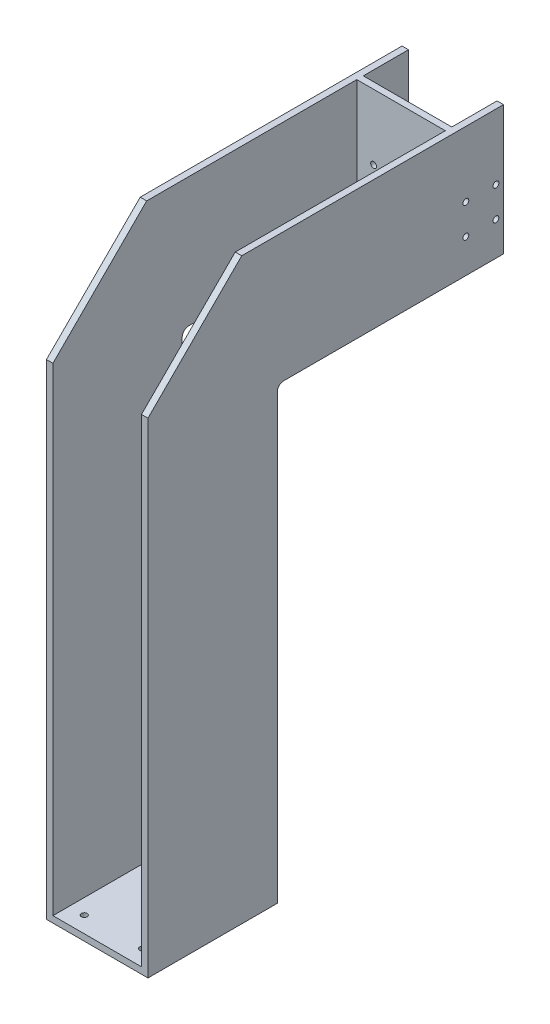
from build123d import *

# Parameters (mm, degrees)
BOSS_EXTRUDE1_DEPTH      = 10
BOSS_EXTRUDE1_DEPTH_BACK = 147
SKETCH3_W                = 137
SKETCH3_H                = 550
CUT_EXTRUDE1_DEPTH       = 885
SKETCH4_W                = 137
SKETCH4_H                = 200
BOSS_EXTRUDE2_DEPTH      = 10
SKETCH5_R                = 4.5
CUT_EXTRUDE2_DEPTH       = 158
CUT_EXTRUDE3_REACH       = 82
SKETCH6_R                = 4.5
SKETCH6_R_2              = 8
CUT_EXTRUDE4_REACH       = 12
SKETCH7_R                = 4.5
SKETCH7_R_2              = 5
FILLET1_R                = 10


with BuildPart() as part:
    # Sketch1 → Boss-Extrude1 (new body, two sides)
    with BuildSketch(Plane(origin=(0, 0, 0), x_dir=(0, 0, -1), z_dir=(1, 0, 0))) as boss_extrude1_sk:
        Polygon((0, 0), (0, 750), (145, 895), (550, 895), (550, 695), (200, 695), (200, 0), align=None)
    extrude(amount=BOSS_EXTRUDE1_DEPTH)
    extrude(boss_extrude1_sk.sketch, amount=-BOSS_EXTRUDE1_DEPTH_BACK)

    # Sketch3 → Cut-Extrude1 (cut)
    with BuildSketch(Plane(origin=(0, 895, 0), x_dir=(1, 0, 0), z_dir=(0, 1, 0))):
        with Locations((-68.5, 275)):
            Rectangle(SKETCH3_W, SKETCH3_H)
    extrude(amount=-CUT_EXTRUDE1_DEPTH, mode=Mode.SUBTRACT)

    # Sketch4 → Boss-Extrude2 (add)
    with BuildSketch(Plane(origin=(0, 0, -480), x_dir=(-1, 0, 0), z_dir=(0, 0, -1))):
        with Locations((68.5, 795)):
            Rectangle(SKETCH4_W, SKETCH4_H)
    extrude(amount=-BOSS_EXTRUDE2_DEPTH)

    # Sketch5 → Cut-Extrude2 (cut, through all)
    with BuildSketch(Plane(origin=(10, 0, 0), x_dir=(0, 0, -1), z_dir=(1, 0, 0))):
        with Locations((538.25, 747.2)):
            Circle(SKETCH5_R)
        with Locations((538.25, 793.7)):
            Circle(SKETCH5_R)
        with Locations((491.75, 747.2)):
            Circle(SKETCH5_R)
        with Locations((491.75, 793.7)):
            Circle(SKETCH5_R)
    extrude(amount=-CUT_EXTRUDE2_DEPTH, mode=Mode.SUBTRACT)

    # Sketch6 → Cut-Extrude3 (cut, up to next)
    with BuildSketch(Plane.XY.offset(-470), mode=Mode.PRIVATE) as cut_extrude3_sk1:
        with Locations((-111, 747.2)):
            Circle(SKETCH6_R)
    cut_extrude3_tool1 = extrude(cut_extrude3_sk1.sketch, amount=-CUT_EXTRUDE3_REACH, mode=Mode.PRIVATE) & part.part
    add(cut_extrude3_tool1.solids().sort_by_distance((-111, 747.2, -470))[0], mode=Mode.SUBTRACT)
    # Sketch6 → Cut-Extrude3 (cut, up to next)
    with BuildSketch(Plane.XY.offset(-470), mode=Mode.PRIVATE) as cut_extrude3_sk2:
        with Locations((-26, 747.2)):
            Circle(SKETCH6_R)
    cut_extrude3_tool2 = extrude(cut_extrude3_sk2.sketch, amount=-CUT_EXTRUDE3_REACH, mode=Mode.PRIVATE) & part.part
    add(cut_extrude3_tool2.solids().sort_by_distance((-26, 747.2, -470))[0], mode=Mode.SUBTRACT)
    # Sketch6 → Cut-Extrude3 (cut, up to next)
    with BuildSketch(Plane.XY.offset(-470), mode=Mode.PRIVATE) as cut_extrude3_sk3:
        with Locations((-111, 793.7)):
            Circle(SKETCH6_R)
    cut_extrude3_tool3 = extrude(cut_extrude3_sk3.sketch, amount=-CUT_EXTRUDE3_REACH, mode=Mode.PRIVATE) & part.part
    add(cut_extrude3_tool3.solids().sort_by_distance((-111, 793.7, -470))[0], mode=Mode.SUBTRACT)
    # Sketch6 → Cut-Extrude3 (cut, up to next)
    with BuildSketch(Plane.XY.offset(-470), mode=Mode.PRIVATE) as cut_extrude3_sk4:
        with Locations((-26, 793.7)):
            Circle(SKETCH6_R)
    cut_extrude3_tool4 = extrude(cut_extrude3_sk4.sketch, amount=-CUT_EXTRUDE3_REACH, mode=Mode.PRIVATE) & part.part
    add(cut_extrude3_tool4.solids().sort_by_distance((-26, 793.7, -470))[0], mode=Mode.SUBTRACT)
    # Sketch6 → Cut-Extrude3 (cut, up to next)
    with BuildSketch(Plane.XY.offset(-470), mode=Mode.PRIVATE) as cut_extrude3_sk5:
        with Locations((-63, 788.5)):
            Circle(SKETCH6_R_2)
    cut_extrude3_tool5 = extrude(cut_extrude3_sk5.sketch, amount=-CUT_EXTRUDE3_REACH, mode=Mode.PRIVATE) & part.part
    add(cut_extrude3_tool5.solids().sort_by_distance((-63, 788.5, -470))[0], mode=Mode.SUBTRACT)

    # Sketch7 → Cut-Extrude4 (cut, up to next)
    with BuildSketch(Plane(origin=(0, 10, 0), x_dir=(1, 0, 0), z_dir=(0, 1, 0)), mode=Mode.PRIVATE) as cut_extrude4_sk1:
        with Locations((-113.5, 175)):
            Circle(SKETCH7_R)
    cut_extrude4_tool1 = extrude(cut_extrude4_sk1.sketch, amount=-CUT_EXTRUDE4_REACH, mode=Mode.PRIVATE) & part.part
    add(cut_extrude4_tool1.solids().sort_by_distance((-113.5, 10, -175))[0], mode=Mode.SUBTRACT)
    # Sketch7 → Cut-Extrude4 (cut, up to next)
    with BuildSketch(Plane(origin=(0, 10, 0), x_dir=(1, 0, 0), z_dir=(0, 1, 0)), mode=Mode.PRIVATE) as cut_extrude4_sk2:
        with Locations((-23.5, 175)):
            Circle(SKETCH7_R)
    cut_extrude4_tool2 = extrude(cut_extrude4_sk2.sketch, amount=-CUT_EXTRUDE4_REACH, mode=Mode.PRIVATE) & part.part
    add(cut_extrude4_tool2.solids().sort_by_distance((-23.5, 10, -175))[0], mode=Mode.SUBTRACT)
    # Sketch7 → Cut-Extrude4 (cut, up to next)
    with BuildSketch(Plane(origin=(0, 10, 0), x_dir=(1, 0, 0), z_dir=(0, 1, 0)), mode=Mode.PRIVATE) as cut_extrude4_sk3:
        with Locations((-23.5, 25)):
            Circle(SKETCH7_R)
    cut_extrude4_tool3 = extrude(cut_extrude4_sk3.sketch, amount=-CUT_EXTRUDE4_REACH, mode=Mode.PRIVATE) & part.part
    add(cut_extrude4_tool3.solids().sort_by_distance((-23.5, 10, -25))[0], mode=Mode.SUBTRACT)
    # Sketch7 → Cut-Extrude4 (cut, up to next)
    with BuildSketch(Plane(origin=(0, 10, 0), x_dir=(1, 0, 0), z_dir=(0, 1, 0)), mode=Mode.PRIVATE) as cut_extrude4_sk4:
        with Locations((-113.5, 25)):
            Circle(SKETCH7_R)
    cut_extrude4_tool4 = extrude(cut_extrude4_sk4.sketch, amount=-CUT_EXTRUDE4_REACH, mode=Mode.PRIVATE) & part.part
    add(cut_extrude4_tool4.solids().sort_by_distance((-113.5, 10, -25))[0], mode=Mode.SUBTRACT)
    # Sketch7 → Cut-Extrude4 (cut, up to next)
    with BuildSketch(Plane(origin=(0, 10, 0), x_dir=(1, 0, 0), z_dir=(0, 1, 0)), mode=Mode.PRIVATE) as cut_extrude4_sk5:
        with Locations((-113.5, 155)):
            Circle(SKETCH7_R_2)
    cut_extrude4_tool5 = extrude(cut_extrude4_sk5.sketch, amount=-CUT_EXTRUDE4_REACH, mode=Mode.PRIVATE) & part.part
    add(cut_extrude4_tool5.solids().sort_by_distance((-113.5, 10, -155))[0], mode=Mode.SUBTRACT)
    # Sketch7 → Cut-Extrude4 (cut, up to next)
    with BuildSketch(Plane(origin=(0, 10, 0), x_dir=(1, 0, 0), z_dir=(0, 1, 0)), mode=Mode.PRIVATE) as cut_extrude4_sk6:
        with Locations((-23.5, 45)):
            Circle(SKETCH7_R_2)
    cut_extrude4_tool6 = extrude(cut_extrude4_sk6.sketch, amount=-CUT_EXTRUDE4_REACH, mode=Mode.PRIVATE) & part.part
    add(cut_extrude4_tool6.solids().sort_by_distance((-23.5, 10, -45))[0], mode=Mode.SUBTRACT)

    # Fillet1
    fillet1_edges = [part.edges().sort_by_distance(p)[0] for p in [
        (-142, 695, -200),
        (5, 695, -200),
    ]]
    fillet(fillet1_edges, radius=FILLET1_R)


solid = part.part
